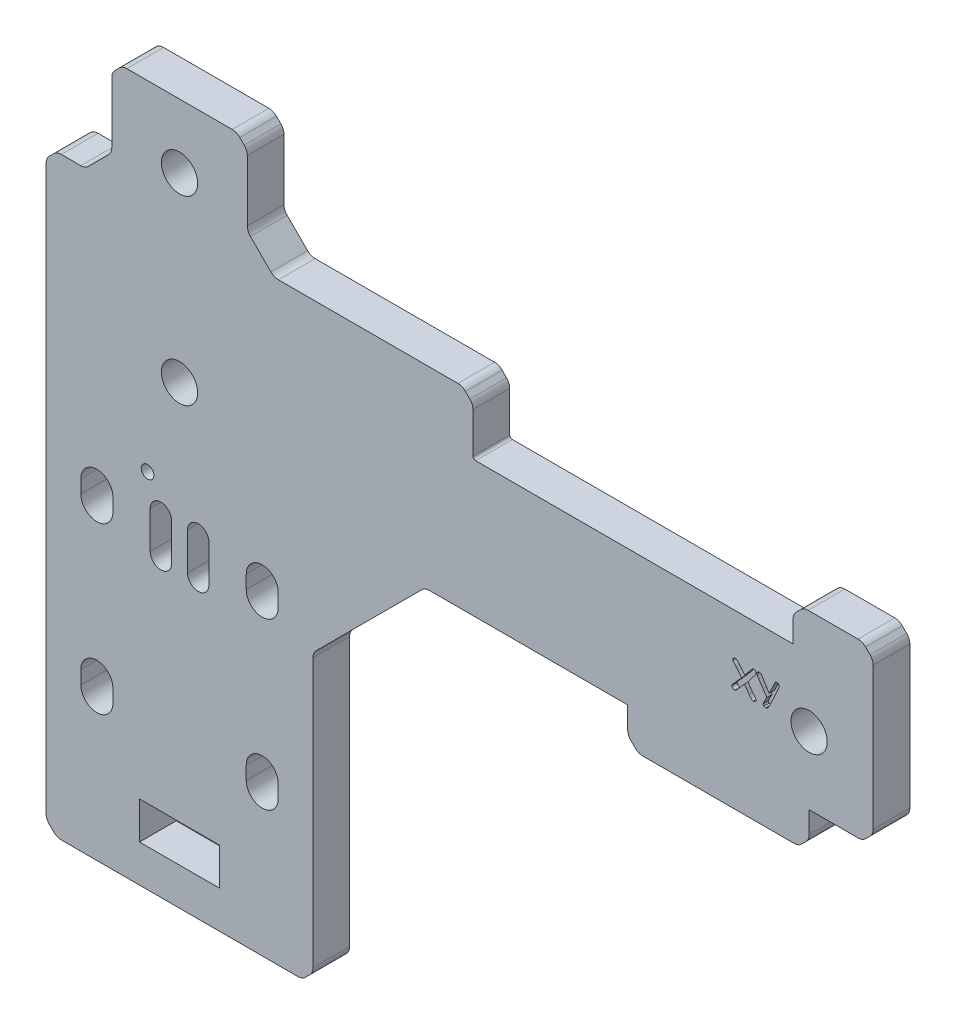
from build123d import *

# Parameters (mm, degrees)
SKETCH1_W           = 50
SKETCH1_H           = 131.35
BOSS_EXTRUDE1_DEPTH = 6.88
SKETCH2_R           = 11.075
SKETCH2_R_2         = 1.75
SKETCH2_R_3         = 3.4
CUT_EXTRUDE1_DEPTH  = 7.88
SKETCH3_W           = 15
SKETCH3_H           = 7
CUT_EXTRUDE2_DEPTH  = 6.88
SKETCH4_W           = 105
SKETCH4_H           = 25.4
BOSS_EXTRUDE2_DEPTH = 6.88
SKETCH5_R           = 3.4
CUT_EXTRUDE3_DEPTH  = 6.88
SKETCH6_W           = 34
SKETCH6_H           = 6.88
SKETCH6_W_2         = 15
BOSS_EXTRUDE3_DEPTH = 6.88
SKETCH7_W           = 12.3
SKETCH7_H           = 20.07
CUT_EXTRUDE4_DEPTH  = 6.88
SKETCH8_R           = 1.1811
CUT_EXTRUDE5_DEPTH  = 6.88
SKETCH9_R           = 3
CUT_EXTRUDE6_DEPTH  = 6.88
SKETCH10_R          = 13
BOSS_EXTRUDE4_DEPTH = 6.88
SKETCH11_W          = 30
SKETCH11_H          = 10.88
BOSS_EXTRUDE5_DEPTH = 6.88
CHAMFER2_SIZE       = 21
CUT_EXTRUDE8_DEPTH  = 10
CUT_EXTRUDE9_DEPTH  = 7.88
CHAMFER5_SIZE       = 5
CHAMFER3_SIZE       = 2
SKETCH15_R          = 7.271476321
BOSS_EXTRUDE6_DEPTH = 6.88
FILLET1_R           = 2
FILLET3_R           = 0.5
CUT_EXTRUDE11_DEPTH = 1


with BuildPart() as part:
    # Sketch1 → Boss-Extrude1 (new body)
    with BuildSketch(Plane.XY):
        Rectangle(SKETCH1_W, SKETCH1_H)
    extrude(amount=BOSS_EXTRUDE1_DEPTH)

    # Sketch2 → Cut-Extrude1 (cut, through all)
    with BuildSketch(Plane.XY.offset(6.88)):
        with Locations((0, -20.675)):
            Circle(SKETCH2_R)
        with Locations((-15.5, -5.175)):
            Circle(SKETCH2_R_2)
        with Locations((-15.5, -36.175)):
            Circle(SKETCH2_R_2)
        with Locations((15.5, -36.175)):
            Circle(SKETCH2_R_2)
        with Locations((15.5, -5.175)):
            Circle(SKETCH2_R_2)
        with Locations((0, 53.675)):
            Circle(SKETCH2_R_3)
        with Locations((0, 19.675)):
            Circle(SKETCH2_R_3)
    extrude(amount=-CUT_EXTRUDE1_DEPTH, mode=Mode.SUBTRACT)

    # Sketch3 → Cut-Extrude2 (cut)
    with BuildSketch(Plane.XY.offset(6.88)):
        with Locations((0, -55.175)):
            Rectangle(SKETCH3_W, SKETCH3_H)
    extrude(amount=-CUT_EXTRUDE2_DEPTH, mode=Mode.SUBTRACT)

    # Sketch4 → Boss-Extrude2 (add)
    with BuildSketch(Plane.XY.offset(6.88)):
        with Locations((77.5, 22.025)):
            Rectangle(SKETCH4_W, SKETCH4_H)
    extrude(amount=-BOSS_EXTRUDE2_DEPTH)

    # Sketch5 → Cut-Extrude3 (cut)
    with BuildSketch(Plane.XY.offset(6.88)):
        with Locations((118, 22.025)):
            Circle(SKETCH5_R)
        with Locations((84, 22.025)):
            Circle(SKETCH5_R)
    extrude(amount=-CUT_EXTRUDE3_DEPTH, mode=Mode.SUBTRACT)

    # Sketch6 → Boss-Extrude3 (add)
    with BuildSketch(Plane.XY.offset(6.88)):
        with Locations((101, 5.885)):
            Rectangle(SKETCH6_W, SKETCH6_H)
        with Locations((122.5, 38.165)):
            Rectangle(SKETCH6_W_2, SKETCH6_H)
    extrude(amount=-BOSS_EXTRUDE3_DEPTH)

    # Sketch7 → Cut-Extrude4 (cut)
    with BuildSketch(Plane.XY.offset(6.88)):
        with Locations((-18.85, 55.64)):
            Rectangle(SKETCH7_W, SKETCH7_H)
        with Locations((18.85, 55.64)):
            Rectangle(SKETCH7_W, SKETCH7_H)
    extrude(amount=-CUT_EXTRUDE4_DEPTH, mode=Mode.SUBTRACT)

    # Sketch8 → Cut-Extrude5 (cut)
    with BuildSketch(Plane.XY.offset(6.88)):
        with Locations((-6, 2.175)):
            Circle(SKETCH8_R)
    extrude(amount=-CUT_EXTRUDE5_DEPTH, mode=Mode.SUBTRACT)

    # Sketch9 → Cut-Extrude6 (cut)
    with BuildSketch(Plane.XY.offset(6.88)):
        with Locations((15.5, -36.175)):
            Circle(SKETCH9_R)
        with Locations((-15.5, -36.175)):
            Circle(SKETCH9_R)
        with Locations((-15.5, -5.175)):
            Circle(SKETCH9_R)
        with Locations((15.5, -5.175)):
            Circle(SKETCH9_R)
    extrude(amount=-CUT_EXTRUDE6_DEPTH, mode=Mode.SUBTRACT)

    # Sketch10 → Boss-Extrude4 (add)
    with BuildSketch(Plane.XY.offset(6.88)):
        with Locations((0, -20.675)):
            Circle(SKETCH10_R)
    extrude(amount=-BOSS_EXTRUDE4_DEPTH)

    # Sketch11 → Boss-Extrude5 (add)
    with BuildSketch(Plane.XY.offset(6.88)):
        with Locations((40, 40.165)):
            Rectangle(SKETCH11_W, SKETCH11_H)
    extrude(amount=-BOSS_EXTRUDE5_DEPTH)

    # Chamfer2
    chamfer2_edges = [part.edges().sort_by_distance(p)[0] for p in [
        (25, 9.325, 3.44),
    ]]
    chamfer(chamfer2_edges, length=CHAMFER2_SIZE)

    # Sketch13 → Cut-Extrude8 (cut)
    with BuildSketch(Plane.XY.offset(6.88)):
        with BuildLine():
            Line((-12.5, -5.175), (-12.5, -7.675))
            ThreePointArc((-12.5, -7.675), (-15.5, -10.675), (-18.5, -7.675))
            Line((-18.5, -7.675), (-18.5, -5.175))
            ThreePointArc((-18.5, -5.175), (-15.5, -2.175), (-12.5, -5.175))
        make_face()
        with BuildLine():
            Line((18.5, -5.175), (18.5, -7.675))
            ThreePointArc((18.5, -7.675), (15.5, -10.675), (12.5, -7.675))
            Line((12.5, -7.675), (12.5, -5.175))
            ThreePointArc((12.5, -5.175), (15.5, -2.175), (18.5, -5.175))
        make_face()
        with BuildLine():
            Line((18.5, -36.175), (18.5, -38.675))
            ThreePointArc((18.5, -38.675), (15.5, -41.675), (12.5, -38.675))
            Line((12.5, -38.675), (12.5, -36.175))
            ThreePointArc((12.5, -36.175), (15.5, -33.175), (18.5, -36.175))
        make_face()
        with BuildLine():
            Line((-12.5, -36.175), (-12.5, -38.675))
            ThreePointArc((-12.5, -38.675), (-15.5, -41.675), (-18.5, -38.675))
            Line((-18.5, -38.675), (-18.5, -36.175))
            ThreePointArc((-18.5, -36.175), (-15.5, -33.175), (-12.5, -36.175))
        make_face()
    extrude(amount=-CUT_EXTRUDE8_DEPTH, mode=Mode.SUBTRACT)

    # Sketch14 → Cut-Extrude9 (cut, through all)
    with BuildSketch(Plane.XY.offset(6.88)):
        with BuildLine():
            Line((-5.5, -10.5), (-5.5, -3.5))
            ThreePointArc((-5.5, -3.5), (-3.5, -1.5), (-1.5, -3.5))
            Line((-1.5, -3.5), (-1.5, -10.5))
            ThreePointArc((-1.5, -10.5), (-3.5, -12.5), (-5.5, -10.5))
        make_face()
        with BuildLine():
            Line((1.5, -10.5), (1.5, -3.5))
            ThreePointArc((1.5, -3.5), (3.5, -1.5), (5.5, -3.5))
            Line((5.5, -3.5), (5.5, -10.5))
            ThreePointArc((5.5, -10.5), (3.5, -12.5), (1.5, -10.5))
        make_face()
    extrude(amount=-CUT_EXTRUDE9_DEPTH, mode=Mode.SUBTRACT)

    # Chamfer5
    chamfer5_edges = [part.edges().sort_by_distance(p)[0] for p in [
        (-12.7, 45.605, 3.44),
        (12.7, 45.605, 3.44),
    ]]
    chamfer(chamfer5_edges, length=CHAMFER5_SIZE)

    # Chamfer3
    chamfer3_edges = [part.edges().sort_by_distance(p)[0] for p in [
        (115, 41.605, 3.44),
        (-25, 45.605, 3.44),
        (-12.7, 65.675, 3.44),
        (12.7, 65.675, 3.44),
        (55, 45.605, 3.44),
        (130, 9.325, 3.44),
        (25, -65.675, 3.44),
        (-25, -65.675, 3.44),
        (84, 2.445, 3.44),
        (118, 2.445, 3.44),
        (130, 41.605, 3.44),
    ]]
    chamfer(chamfer3_edges, length=CHAMFER3_SIZE)

    # Sketch15 → Boss-Extrude6 (add)
    with BuildSketch(Plane.XY.offset(6.88)):
        with Locations((84, 22.025)):
            Circle(SKETCH15_R)
    extrude(amount=-BOSS_EXTRUDE6_DEPTH)

    # Fillet1
    fillet1_edges = [part.edges().sort_by_distance(p)[0] for p in [
        (25, -11.675, 3.44),
        (46, 9.325, 3.44),
        (-12.7, 50.605, 3.44),
        (-17.7, 45.605, 3.44),
        (17.7, 45.605, 3.44),
        (12.7, 50.605, 3.44),
        (55, 43.605, 3.44),
        (53, 45.605, 3.44),
        (25, -63.675, 3.44),
        (-23, -65.675, 3.44),
        (23, -65.675, 3.44),
        (-25, 43.605, 3.44),
        (-25, -63.675, 3.44),
        (84, 4.445, 3.44),
        (116, 2.445, 3.44),
        (86, 2.445, 3.44),
        (118, 4.445, 3.44),
        (128, 9.325, 3.44),
        (130, 39.605, 3.44),
        (130, 11.325, 3.44),
        (128, 41.605, 3.44),
        (117, 41.605, 3.44),
        (115, 39.605, 3.44),
        (-23, 45.605, 3.44),
        (10.7, 65.675, 3.44),
        (-10.7, 65.675, 3.44),
        (-12.7, 63.675, 3.44),
        (12.7, 63.675, 3.44),
    ]]
    fillet(fillet1_edges, radius=FILLET1_R)

    # Fillet3
    fillet3_edges = [part.edges().sort_by_distance(p)[0] for p in [
        (55, 34.725, 3.44),
    ]]
    fillet(fillet3_edges, radius=FILLET3_R)

    # Sketch18 → Cut-Extrude11 (cut)
    with BuildSketch(Plane.XY.offset(6.88)):
        with BuildLine():
            add(Edge.make_bspline(
                [(112.225501543, 26.027700617), (112.210037307, 25.994922436), (112.175363014, 25.921426386), (112.118415217, 25.798630289), (112.050730421, 25.651278811), (111.974119064, 25.478094901), (111.885048084, 25.281130827), (111.786852832, 25.058746021), (111.677766047, 24.811875789), (111.601752833, 24.63882707), (111.561921296, 24.548148148)],
                knots=[0, 0, 0, 0, 0.000108729, 0.000243794, 0.000406075, 0.000595179, 0.000811902, 0.001054574, 0.001324472, 0.001621596, 0.001621596, 0.001621596, 0.001621596], degree=3))
            add(Edge.make_bspline(
                [(111.561921296, 24.548148148), (111.528362786, 24.470899192), (111.462923964, 24.320264358), (111.364189289, 24.102084243), (111.271122924, 23.895792895), (111.179810803, 23.703490787), (111.09496269, 23.522649003), (111.011165474, 23.356191228), (110.933776439, 23.201149537), (110.881205698, 23.103200926), (110.855902778, 23.056057099)],
                knots=[0, 0, 0, 0, 0.000252666, 0.000492696, 0.000718436, 0.000931581, 0.001131329, 0.001317668, 0.001490638, 0.001651144, 0.001651144, 0.001651144, 0.001651144], degree=3))
            add(Edge.make_bspline(
                [(110.855902778, 23.056057099), (110.8352289, 23.018172274), (110.795195234, 22.944810692), (110.738569543, 22.837256058), (110.684594176, 22.73692412), (110.633375433, 22.644091958), (110.587028229, 22.557287024), (110.543625612, 22.478222717), (110.505281672, 22.40508891), (110.469162238, 22.339911895), (110.438147121, 22.280773232), (110.408049183, 22.230005619), (110.38499358, 22.184383692), (110.363249082, 22.146912202), (110.346043864, 22.11595922), (110.332324676, 22.091973573), (110.323032159, 22.074213008), (110.317110626, 22.065160818), (110.314814815, 22.061651235)],
                knots=[0, 0, 0, 0, 0.000129474, 0.000250718, 0.000364644, 0.000471256, 0.000568786, 0.000659849, 0.000741832, 0.000816498, 0.000883391, 0.000942131, 0.000993477, 0.001036664, 0.001072076, 0.001099713, 0.001119573, 0.001132149, 0.001132149, 0.001132149, 0.001132149], degree=3))
            add(Edge.make_bspline(
                [(110.314814815, 22.061651235), (110.298413024, 22.039230015), (110.266813755, 21.996033871), (110.215852205, 21.93719445), (110.161437851, 21.889112886), (110.10576881, 21.848619074), (110.048292201, 21.816707611), (109.988317837, 21.793718515), (109.926297381, 21.781418419), (109.884370768, 21.779196434), (109.863425926, 21.77808642)],
                knots=[0, 0, 0, 0, 8.3334e-05, 0.000160548, 0.000232957, 0.000300679, 0.000366725, 0.000429603, 0.000492592, 0.00055547, 0.00055547, 0.00055547, 0.00055547], degree=3))
            add(Edge.make_bspline(
                [(109.863425926, 21.77808642), (109.833687099, 21.779546555), (109.775280109, 21.782414258), (109.690836489, 21.805910282), (109.611225576, 21.842237629), (109.564797736, 21.877762121), (109.541280864, 21.895756173)],
                knots=[0, 0, 0, 0, 8.9069e-05, 0.000174932, 0.000261227, 0.000349804, 0.000349804, 0.000349804, 0.000349804], degree=3))
            add(Edge.make_bspline(
                [(109.541280864, 21.895756173), (109.517991812, 21.917971488), (109.472992924, 21.960895711), (109.424636157, 22.040020207), (109.394135006, 22.126334533), (109.390653306, 22.187104779), (109.388888889, 22.217901235)],
                knots=[0, 0, 0, 0, 9.6185e-05, 0.000185848, 0.000275521, 0.000367655, 0.000367655, 0.000367655, 0.000367655], degree=3))
            add(Edge.make_bspline(
                [(109.388888889, 22.217901235), (109.389666866, 22.225969911), (109.391493991, 22.244919676), (109.400086285, 22.277155667), (109.413380739, 22.317176253), (109.433594568, 22.364643974), (109.457432691, 22.420844942), (109.487294708, 22.484723699), (109.522383527, 22.556724903), (109.562673035, 22.636586131), (109.609469584, 22.724251785), (109.660062662, 22.820338259), (109.716281383, 22.924395983), (109.779367452, 23.035704799), (109.846220956, 23.15599699), (109.919119926, 23.283822043), (109.996927834, 23.419681392), (110.051421302, 23.5126383), (110.079475309, 23.560493827)],
                knots=[0, 0, 0, 0, 2.4286e-05, 5.7036e-05, 9.9737e-05, 0.000150783, 0.0002117, 0.000282903, 0.000362275, 0.000451994, 0.000551226, 0.000660386, 0.000777775, 0.000906025, 0.001044205, 0.001190636, 0.001347474, 0.00151389, 0.00151389, 0.00151389, 0.00151389], degree=3))
            add(Edge.make_bspline(
                [(110.079475309, 23.560493827), (110.056963864, 23.592639548), (110.009281832, 23.660728171), (109.93400875, 23.768503025), (109.852157812, 23.888196338), (109.763108434, 24.019483501), (109.668256067, 24.162977181), (109.565497417, 24.317808564), (109.455761827, 24.484280208), (109.380485538, 24.599559464), (109.341628086, 24.659066358)],
                knots=[0, 0, 0, 0, 0.000117733, 0.000249373, 0.000394373, 0.00055274, 0.000725282, 0.000910397, 0.001110227, 0.001323437, 0.001323437, 0.001323437, 0.001323437], degree=3))
            add(Edge.make_bspline(
                [(109.341628086, 24.659066358), (109.309755144, 24.706940916), (109.242253182, 24.808331824), (109.136308256, 24.969504766), (109.019391295, 25.147593895), (108.893693214, 25.343907428), (108.754937357, 25.555994855), (108.607012924, 25.786057499), (108.448704828, 26.033621895), (108.339222079, 26.2039077), (108.282600309, 26.291975309)],
                knots=[0, 0, 0, 0, 0.000172542, 0.000365416, 0.000578627, 0.00081165, 0.001064728, 0.001338955, 0.00163219, 0.001946288, 0.001946288, 0.001946288, 0.001946288], degree=3))
            add(Edge.make_bspline(
                [(108.282600309, 26.291975309), (108.272448352, 26.3103858), (108.252361027, 26.346814004), (108.231511721, 26.404650977), (108.217962923, 26.463671826), (108.216689761, 26.503449387), (108.216049383, 26.52345679)],
                knots=[0, 0, 0, 0, 6.2982e-05, 0.000124619, 0.000183833, 0.000243756, 0.000243756, 0.000243756, 0.000243756], degree=3))
            add(Edge.make_bspline(
                [(108.216049383, 26.52345679), (108.217983791, 26.553883839), (108.221788442, 26.613728642), (108.249735602, 26.699750584), (108.297008872, 26.778084134), (108.34101552, 26.820778869), (108.363618827, 26.842708333)],
                knots=[0, 0, 0, 0, 9.1175e-05, 0.000179326, 0.000268484, 0.000362641, 0.000362641, 0.000362641, 0.000362641], degree=3))
            add(Edge.make_bspline(
                [(108.363618827, 26.842708333), (108.387107366, 26.861337019), (108.433072884, 26.897792127), (108.512480669, 26.936028448), (108.597369703, 26.958736541), (108.656046192, 26.961746938), (108.685763889, 26.963271605)],
                knots=[0, 0, 0, 0, 8.9704e-05, 0.000175545, 0.00026234, 0.00035141, 0.00035141, 0.00035141, 0.00035141], degree=3))
            add(Edge.make_bspline(
                [(108.685763889, 26.963271605), (108.721516659, 26.960651208), (108.793731898, 26.955358398), (108.897904029, 26.911648765), (108.995386715, 26.840728262), (109.050862236, 26.778339659), (109.080246914, 26.74529321)],
                knots=[0, 0, 0, 0, 0.000106952, 0.000216026, 0.00033353, 0.000465867, 0.000465867, 0.000465867, 0.000465867], degree=3))
            Line((109.080246914, 26.74529321), (109.331983025, 26.353703704))
            add(Edge.make_bspline(
                [(109.331983025, 26.353703704), (109.333541214, 26.350779979), (109.337827811, 26.34273678), (109.348373799, 26.328385049), (109.361147936, 26.30606193), (109.378760035, 26.277283387), (109.399750959, 26.241263012), (109.426093515, 26.199202606), (109.455670843, 26.149618895), (109.490825948, 26.094335183), (109.527927507, 26.030937839), (109.57106476, 25.961790827), (109.616434806, 25.884515564), (109.668481408, 25.801685874), (109.722638397, 25.711165485), (109.782217283, 25.614523515), (109.844391142, 25.510169081), (109.8881087, 25.438664704), (109.910686728, 25.401736111)],
                knots=[0, 0, 0, 0, 9.93e-06, 2.7318e-05, 5.3288e-05, 8.7032e-05, 0.000128551, 0.000178342, 0.000235906, 0.000301747, 0.000374859, 0.000456244, 0.000546228, 0.000643662, 0.000749692, 0.000862671, 0.000984249, 0.0011141, 0.0011141, 0.0011141, 0.0011141], degree=3))
            add(Edge.make_bspline(
                [(109.910686728, 25.401736111), (109.939192317, 25.354409661), (109.995040211, 25.261688105), (110.078522375, 25.12721387), (110.159798237, 25.000693683), (110.237985718, 24.881548328), (110.314106241, 24.770140966), (110.386865335, 24.665642699), (110.45879893, 24.570122928), (110.506041653, 24.509193995), (110.528935185, 24.47966821)],
                knots=[0, 0, 0, 0, 0.000165744, 0.000324723, 0.000474818, 0.000616866, 0.00075223, 0.000879604, 0.000998817, 0.001110903, 0.001110903, 0.001110903, 0.001110903], degree=3))
            add(Edge.make_bspline(
                [(110.528935185, 24.47966821), (110.551240942, 24.523975251), (110.598310671, 24.617472211), (110.670151225, 24.766568284), (110.750792634, 24.930889819), (110.838291273, 25.111399008), (110.931654845, 25.308406554), (111.032041967, 25.521033941), (111.140265361, 25.749377261), (111.214131779, 25.907423232), (111.252314815, 25.98912037)],
                knots=[0, 0, 0, 0, 0.000148812, 0.000314025, 0.00049649, 0.000697942, 0.000915812, 0.001150518, 0.001403346, 0.001673884, 0.001673884, 0.001673884, 0.001673884], degree=3))
            add(Edge.make_bspline(
                [(111.252314815, 25.98912037), (111.260963003, 26.009067716), (111.279401816, 26.051597476), (111.309304249, 26.118648862), (111.342018604, 26.19295054), (111.377930621, 26.27419193), (111.416463823, 26.362948366), (111.457785674, 26.45914282), (111.501979757, 26.562559905), (111.533235211, 26.633441942), (111.549382716, 26.670061728)],
                knots=[0, 0, 0, 0, 6.5224e-05, 0.000139064, 0.000220248, 0.000308778, 0.000405537, 0.000510527, 0.000622862, 0.000742926, 0.000742926, 0.000742926, 0.000742926], degree=3))
            add(Edge.make_bspline(
                [(111.549382716, 26.670061728), (111.559717292, 26.693195521), (111.579738237, 26.738012103), (111.618531481, 26.798019908), (111.662430085, 26.848890458), (111.71093644, 26.891454701), (111.766127336, 26.923501287), (111.826272017, 26.946852851), (111.892145114, 26.960502225), (111.937693155, 26.962328176), (111.961226852, 26.963271605)],
                knots=[0, 0, 0, 0, 7.5927e-05, 0.000147092, 0.000213418, 0.000277025, 0.000339718, 0.000403841, 0.000469859, 0.000540432, 0.000540432, 0.000540432, 0.000540432], degree=3))
            add(Edge.make_bspline(
                [(111.961226852, 26.963271605), (111.989304835, 26.961610193), (112.044978454, 26.958315912), (112.126215399, 26.937360711), (112.201055369, 26.898141995), (112.245309088, 26.863379104), (112.267939815, 26.845601852)],
                knots=[0, 0, 0, 0, 8.4266e-05, 0.000167085, 0.000249475, 0.000335705, 0.000335705, 0.000335705, 0.000335705], degree=3))
            add(Edge.make_bspline(
                [(112.267939815, 26.845601852), (112.290273915, 26.824009835), (112.333748386, 26.781979867), (112.379631508, 26.703905771), (112.409568418, 26.618203777), (112.412220812, 26.557475462), (112.413580247, 26.526350309)],
                knots=[0, 0, 0, 0, 9.2793e-05, 0.000180627, 0.000269078, 0.000362077, 0.000362077, 0.000362077, 0.000362077], degree=3))
            add(Edge.make_bspline(
                [(112.413580247, 26.526350309), (112.412880984, 26.515702749), (112.411275284, 26.491253029), (112.401347377, 26.450441374), (112.387441923, 26.40058655), (112.365050676, 26.342951709), (112.33966335, 26.2758723), (112.306000345, 26.20125074), (112.268973908, 26.116773996), (112.240514637, 26.058461929), (112.225501543, 26.027700617)],
                knots=[0, 0, 0, 0, 3.196e-05, 7.3389e-05, 0.000125588, 0.000187226, 0.000258691, 0.000340759, 0.000432716, 0.00053539, 0.00053539, 0.00053539, 0.00053539], degree=3))
        make_face()
        with BuildLine():
            add(Edge.make_bspline(
                [(107.972993827, 26.224459877), (107.938156654, 26.184370818), (107.870242529, 26.106218286), (107.772789277, 25.990220191), (107.681573978, 25.879285396), (107.59481944, 25.774488289), (107.51685534, 25.673026198), (107.442425508, 25.578401948), (107.375484466, 25.487927465), (107.332838591, 25.429095671), (107.312307099, 25.400771605)],
                knots=[0, 0, 0, 0, 0.00015933, 0.00031061, 0.00045448, 0.000590205, 0.000718702, 0.000838316, 0.000951357, 0.001056307, 0.001056307, 0.001056307, 0.001056307], degree=3))
            add(Edge.make_bspline(
                [(107.312307099, 25.400771605), (107.290165467, 25.368913718), (107.243281322, 25.301455737), (107.168048992, 25.195121237), (107.082936618, 25.078815024), (106.989785876, 24.951278364), (106.88611409, 24.814337558), (106.773308405, 24.666733656), (106.651033885, 24.50895174), (106.566148905, 24.400541105), (106.522376543, 24.344637346)],
                knots=[0, 0, 0, 0, 0.00011639, 0.000246452, 0.000390757, 0.000548751, 0.000720241, 0.000906013, 0.001106075, 0.00131908, 0.00131908, 0.00131908, 0.00131908], degree=3))
            add(Edge.make_bspline(
                [(106.522376543, 24.344637346), (106.634564886, 24.18516115), (106.859199314, 23.865842374), (107.084024689, 23.546658012), (107.196566358, 23.386882716)],
                knots=[0, 0, 0, 0, 0.000584953, 0.00117125, 0.00117125, 0.00117125, 0.00117125], degree=3))
            add(Edge.make_bspline(
                [(107.196566358, 23.386882716), (107.260832405, 23.297564756), (107.384624757, 23.125516202), (107.568519731, 22.882057114), (107.741688374, 22.662034554), (107.857168655, 22.526530138), (107.912229938, 22.461921296)],
                knots=[0, 0, 0, 0, 0.000330095, 0.000635845, 0.000915267, 0.001169912, 0.001169912, 0.001169912, 0.001169912], degree=3))
            add(Edge.make_bspline(
                [(107.912229938, 22.461921296), (107.930485623, 22.439040339), (107.965645008, 22.394972948), (108.002432065, 22.321094315), (108.02631136, 22.245417311), (108.02934635, 22.193641053), (108.030864198, 22.167746914)],
                knots=[0, 0, 0, 0, 8.7579e-05, 0.000168672, 0.000246182, 0.000323727, 0.000323727, 0.000323727, 0.000323727], degree=3))
            add(Edge.make_bspline(
                [(108.030864198, 22.167746914), (108.029275816, 22.137968688), (108.026154966, 22.079460465), (107.998740221, 21.994986153), (107.953064599, 21.917604757), (107.891698358, 21.848559902), (107.819596772, 21.789569952), (107.737717003, 21.747491223), (107.649230574, 21.721231906), (107.587696006, 21.718003691), (107.55632716, 21.716358025)],
                knots=[0, 0, 0, 0, 8.9158e-05, 0.000175178, 0.00026335, 0.000356986, 0.00045098, 0.000541139, 0.000631495, 0.000725454, 0.000725454, 0.000725454, 0.000725454], degree=3))
            add(Edge.make_bspline(
                [(107.55632716, 21.716358025), (107.527727887, 21.718833333), (107.467016125, 21.724088023), (107.375316094, 21.762914851), (107.279419416, 21.822355933), (107.178305675, 21.905675012), (107.071787257, 22.011105537), (106.96029479, 22.140509112), (106.842548476, 22.292193429), (106.765526918, 22.403331656), (106.72492284, 22.461921296)],
                knots=[0, 0, 0, 0, 8.5662e-05, 0.000181847, 0.000294826, 0.000423767, 0.000573815, 0.000744031, 0.000935803, 0.001149621, 0.001149621, 0.001149621, 0.001149621], degree=3))
            add(Edge.make_bspline(
                [(106.72492284, 22.461921296), (106.712673494, 22.480869256), (106.686769345, 22.520939217), (106.646396989, 22.584890153), (106.600926596, 22.655210787), (106.551127976, 22.73228462), (106.495682381, 22.815034008), (106.437061513, 22.905085666), (106.373310488, 23.001475274), (106.329164567, 23.067959842), (106.30632716, 23.102353395)],
                knots=[0, 0, 0, 0, 6.7687e-05, 0.000143141, 0.000226881, 0.000318909, 0.000418422, 0.000525695, 0.000641259, 0.000765114, 0.000765114, 0.000765114, 0.000765114], degree=3))
            add(Edge.make_bspline(
                [(106.30632716, 23.102353395), (106.294421071, 23.119064034), (106.26926417, 23.154372681), (106.22973413, 23.210324907), (106.186103189, 23.272440419), (106.138369845, 23.34039813), (106.08597475, 23.413801374), (106.029858376, 23.493316133), (105.969557521, 23.578614818), (105.927621991, 23.637350053), (105.906057099, 23.667554012)],
                knots=[0, 0, 0, 0, 6.1555e-05, 0.000130062, 0.000205522, 0.000289279, 0.0003792, 0.000476074, 0.000581245, 0.000692582, 0.000692582, 0.000692582, 0.000692582], degree=3))
            add(Edge.make_bspline(
                [(105.906057099, 23.667554012), (105.872285293, 23.628986111), (105.802789087, 23.549620419), (105.695752637, 23.426825375), (105.581837907, 23.297670985), (105.461601485, 23.161703784), (105.333926725, 23.019919433), (105.199905504, 22.87134461), (105.059370662, 22.716414549), (104.963431679, 22.611081301), (104.914544753, 22.557407407)],
                knots=[0, 0, 0, 0, 0.000153793, 0.000316477, 0.000488689, 0.000670432, 0.000860987, 0.001061077, 0.001270704, 0.001488505, 0.001488505, 0.001488505, 0.001488505], degree=3))
            add(Edge.make_bspline(
                [(104.914544753, 22.557407407), (104.897523651, 22.537779819), (104.861698116, 22.496468225), (104.80475518, 22.431588106), (104.740775678, 22.361141538), (104.670342938, 22.284296685), (104.594510897, 22.200078582), (104.511102414, 22.110479458), (104.421786962, 22.013991299), (104.359378017, 21.948098033), (104.327160494, 21.91408179)],
                knots=[0, 0, 0, 0, 7.794e-05, 0.000164046, 0.000258966, 0.000363422, 0.000476767, 0.00059894, 0.000730654, 0.000871208, 0.000871208, 0.000871208, 0.000871208], degree=3))
            add(Edge.make_bspline(
                [(104.327160494, 21.91408179), (104.303159182, 21.893096597), (104.256350334, 21.852169971), (104.174283505, 21.809339056), (104.08699168, 21.783155801), (104.026737312, 21.779786474), (103.996334877, 21.77808642)],
                knots=[0, 0, 0, 0, 9.535e-05, 0.000185957, 0.000275386, 0.000366464, 0.000366464, 0.000366464, 0.000366464], degree=3))
            add(Edge.make_bspline(
                [(103.996334877, 21.77808642), (103.965641448, 21.7798593), (103.905213356, 21.78334968), (103.817343274, 21.808091325), (103.736592283, 21.850574211), (103.663647042, 21.907247939), (103.602342938, 21.975204262), (103.55801564, 22.052563029), (103.529185444, 22.13584675), (103.526200116, 22.19419804), (103.524691358, 22.223688272)],
                knots=[0, 0, 0, 0, 9.2038e-05, 0.000181202, 0.000271361, 0.000364159, 0.000457073, 0.000543927, 0.000630243, 0.000718442, 0.000718442, 0.000718442, 0.000718442], degree=3))
            add(Edge.make_bspline(
                [(103.524691358, 22.223688272), (103.525873764, 22.249255839), (103.528235752, 22.300329929), (103.551167191, 22.374582763), (103.585533931, 22.446475275), (103.619264268, 22.488553046), (103.636574074, 22.510146605)],
                knots=[0, 0, 0, 0, 7.6495e-05, 0.000152806, 0.000231312, 0.000314068, 0.000314068, 0.000314068, 0.000314068], degree=3))
            add(Edge.make_bspline(
                [(103.636574074, 22.510146605), (103.653998217, 22.528413311), (103.691052666, 22.567259567), (103.748267388, 22.629921289), (103.812303042, 22.698670607), (103.882730559, 22.773584923), (103.958500524, 22.855643227), (104.04123074, 22.943362965), (104.128273847, 23.039177584), (104.189462774, 23.104370274), (104.221064815, 23.138040123)],
                knots=[0, 0, 0, 0, 7.5731e-05, 0.00016105, 0.000254547, 0.000357587, 0.000469511, 0.000589615, 0.000719311, 0.000857841, 0.000857841, 0.000857841, 0.000857841], degree=3))
            add(Edge.make_bspline(
                [(104.221064815, 23.138040123), (104.257759114, 23.178188798), (104.334532678, 23.262189772), (104.453421289, 23.394036508), (104.582402329, 23.535830789), (104.718912034, 23.689559224), (104.865598386, 23.853164474), (105.02114352, 24.027834413), (105.184487468, 24.213891015), (105.296781537, 24.341126565), (105.354359568, 24.406365741)],
                knots=[0, 0, 0, 0, 0.000163173, 0.000341398, 0.000532599, 0.00073821, 0.00095816, 0.001191806, 0.001439871, 0.001700912, 0.001700912, 0.001700912, 0.001700912], degree=3))
            add(Edge.make_bspline(
                [(105.354359568, 24.406365741), (105.244014481, 24.546630233), (105.020930939, 24.830201532), (104.786877784, 25.104789929), (104.668595679, 25.243557099)],
                knots=[0, 0, 0, 0, 0.000535342, 0.001082295, 0.001082295, 0.001082295, 0.001082295], degree=3))
            add(Edge.make_bspline(
                [(104.668595679, 25.243557099), (104.664738465, 25.248380184), (104.65344899, 25.262496613), (104.63151667, 25.289842822), (104.600924175, 25.331060369), (104.559088963, 25.383331974), (104.509055253, 25.449829174), (104.44827291, 25.528090571), (104.378806747, 25.620514325), (104.328815663, 25.685980268), (104.302083333, 25.720987654)],
                knots=[0, 0, 0, 0, 1.8528e-05, 5.4227e-05, 0.000105155, 0.000172491, 0.000255056, 0.000354793, 0.000469763, 0.000601904, 0.000601904, 0.000601904, 0.000601904], degree=3))
            add(Edge.make_bspline(
                [(104.302083333, 25.720987654), (104.266151648, 25.766967473), (104.197940737, 25.854253255), (104.094318768, 25.973938993), (103.995162359, 26.075721486), (103.898031996, 26.157353245), (103.813297947, 26.233452228), (103.753412462, 26.319743456), (103.716461403, 26.413548995), (103.712072346, 26.479092123), (103.709876543, 26.511882716)],
                knots=[0, 0, 0, 0, 0.000175033, 0.000332274, 0.000474816, 0.000600572, 0.000713122, 0.000815055, 0.000913041, 0.001011141, 0.001011141, 0.001011141, 0.001011141], degree=3))
            add(Edge.make_bspline(
                [(103.709876543, 26.511882716), (103.711653383, 26.540342591), (103.715171394, 26.596691047), (103.740372793, 26.678992347), (103.782883596, 26.755951494), (103.840408278, 26.82641306), (103.909551454, 26.88710035), (103.989635066, 26.931637128), (104.07852763, 26.958719993), (104.140817502, 26.961726182), (104.172839506, 26.963271605)],
                knots=[0, 0, 0, 0, 8.5319e-05, 0.000168926, 0.000255678, 0.000347564, 0.000440568, 0.00052994, 0.000620568, 0.000716447, 0.000716447, 0.000716447, 0.000716447], degree=3))
            add(Edge.make_bspline(
                [(104.172839506, 26.963271605), (104.188333181, 26.962461041), (104.220680026, 26.96076879), (104.270283896, 26.948330456), (104.322948402, 26.928228392), (104.379728378, 26.901888573), (104.438373715, 26.864545914), (104.502505136, 26.822967129), (104.568380237, 26.771333804), (104.612778335, 26.733861527), (104.635802469, 26.714429012)],
                knots=[0, 0, 0, 0, 4.6457e-05, 9.699e-05, 0.000152531, 0.00021552, 0.000284332, 0.000360838, 0.000444756, 0.000535152, 0.000535152, 0.000535152, 0.000535152], degree=3))
            add(Edge.make_bspline(
                [(104.635802469, 26.714429012), (104.668586944, 26.684208402), (104.732639861, 26.625164655), (104.821270537, 26.533220336), (104.902198546, 26.441748923), (104.975653033, 26.344460182), (105.053718401, 26.237382352), (105.145118073, 26.11462809), (105.252345085, 25.971198692), (105.330128534, 25.869753659), (105.371720679, 25.815509259)],
                knots=[0, 0, 0, 0, 0.000133736, 0.000261288, 0.000382962, 0.00049987, 0.000626804, 0.000780548, 0.000958982, 0.001164043, 0.001164043, 0.001164043, 0.001164043], degree=3))
            add(Edge.make_bspline(
                [(105.371720679, 25.815509259), (105.472440199, 25.696507889), (105.673239747, 25.459260718), (105.865306443, 25.214890245), (105.961033951, 25.093094136)],
                knots=[0, 0, 0, 0, 0.000467666, 0.000932363, 0.000932363, 0.000932363, 0.000932363], degree=3))
            add(Edge.make_bspline(
                [(105.961033951, 25.093094136), (106.097684914, 25.274090294), (106.370715517, 25.63572324), (106.643595358, 25.997469961), (106.779899691, 26.17816358)],
                knots=[0, 0, 0, 0, 0.000680366, 0.001359381, 0.001359381, 0.001359381, 0.001359381], degree=3))
            add(Edge.make_bspline(
                [(106.779899691, 26.17816358), (106.830362009, 26.239851993), (106.925407199, 26.356041401), (107.064513599, 26.515719216), (107.190538838, 26.65129163), (107.303786613, 26.762330431), (107.403722568, 26.84995308), (107.491722167, 26.911265494), (107.567108799, 26.952959204), (107.616119088, 26.960155049), (107.637345679, 26.963271605)],
                knots=[0, 0, 0, 0, 0.000239083, 0.00045031, 0.000635236, 0.000794157, 0.000926182, 0.001032933, 0.001116618, 0.001180552, 0.001180552, 0.001180552, 0.001180552], degree=3))
            add(Edge.make_bspline(
                [(107.637345679, 26.963271605), (107.667060995, 26.961465185), (107.725566108, 26.957908609), (107.810752643, 26.933661667), (107.887844005, 26.889024781), (107.958403561, 26.832221433), (108.017774095, 26.76385692), (108.06161218, 26.687002529), (108.087558369, 26.603217899), (108.090898734, 26.545174072), (108.092592593, 26.515740741)],
                knots=[0, 0, 0, 0, 8.9158e-05, 0.000175539, 0.000262757, 0.000354643, 0.000446286, 0.000532662, 0.000618395, 0.000706593, 0.000706593, 0.000706593, 0.000706593], degree=3))
            add(Edge.make_bspline(
                [(108.092592593, 26.515740741), (108.091066026, 26.490170294), (108.088012894, 26.439029401), (108.06411121, 26.363824757), (108.026477098, 26.290839618), (107.991189953, 26.247043652), (107.972993827, 26.224459877)],
                knots=[0, 0, 0, 0, 7.6586e-05, 0.000153171, 0.000234705, 0.00032151, 0.00032151, 0.00032151, 0.00032151], degree=3))
        make_face()
    extrude(amount=-CUT_EXTRUDE11_DEPTH, mode=Mode.SUBTRACT)


solid = part.part
